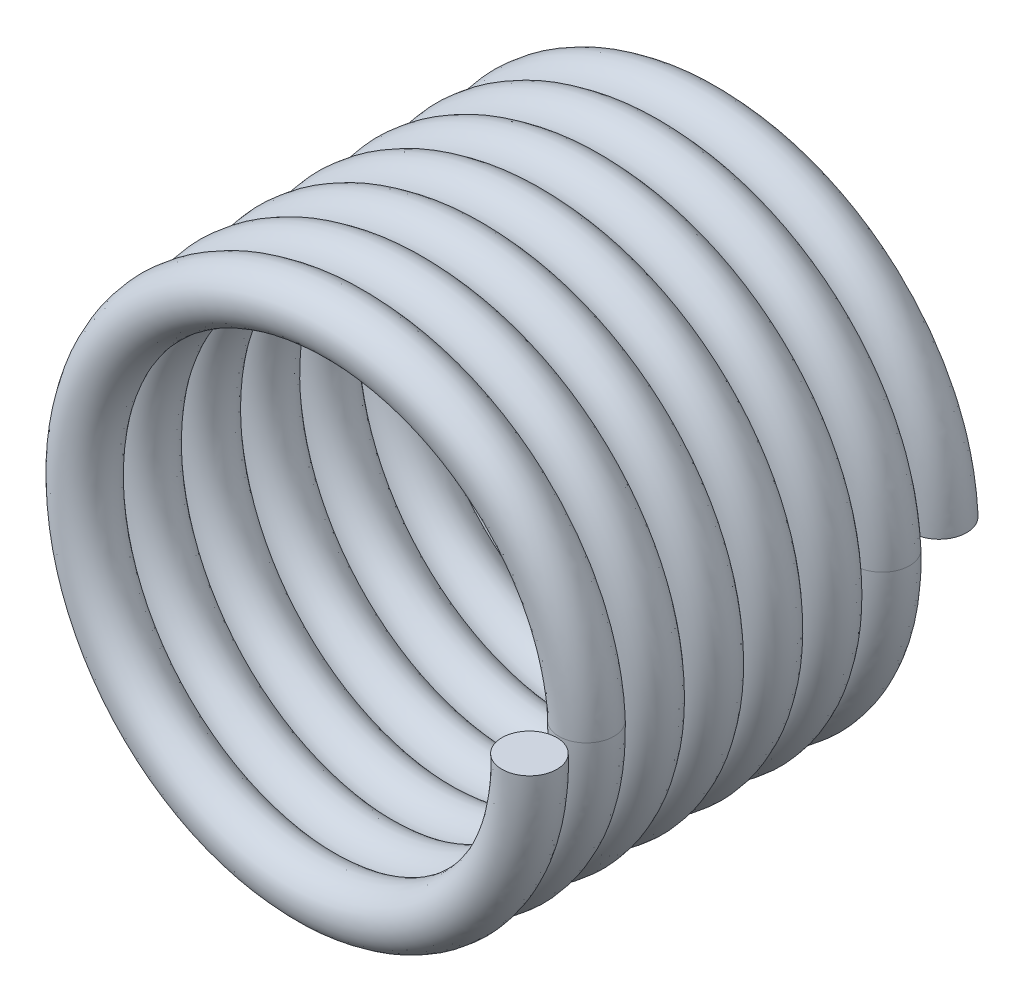
from build123d import *

# Parameters (mm, degrees)
SKETCH5_R = 0.3302


with BuildPart() as part:
    # Sweep1: sweep along a curve in space
    with BuildLine() as sweep1_path:
        add(Edge.make_bspline(
            [(3.175, 0, 0), (3.175, -0.412944338, -0.014195981), (3.009683692, -1.247861375, -0.042904974), (2.303512171, -2.303188068, -0.085713619), (1.246651804, -3.009770535, -0.12859055), (0, -3.257634885, -0.171449183), (-1.246651804, -3.009689925, -0.214312719), (-2.303512171, -2.303510509, -0.257174942), (-3.009683692, -1.246652219, -0.300037515), (-3.257658154, 0, -0.3429), (-3.009683692, 1.246652219, -0.385762485), (-2.303512171, 2.303510509, -0.428625058), (-1.246651804, 3.009689925, -0.471487281), (0, 3.257634885, -0.514350817), (1.246651804, 3.009770535, -0.55720945), (2.303512171, 2.303188068, -0.600086381), (3.009683692, 1.247861375, -0.642895026), (3.175, 0.412944338, -0.671604019), (3.175, 0, -0.6858)],
            knots=[0, 0, 0, 0, 0.0625, 0.125, 0.1875, 0.25, 0.3125, 0.375, 0.4375, 0.5, 0.5625, 0.625, 0.6875, 0.75, 0.8125, 0.875, 0.9375, 1, 1, 1, 1], degree=3))
        add(Edge.make_bspline(
            [(3.175, 0, -0.6858), (3.175, -0.412944576, -0.700521766), (3.009683692, -1.247861264, -0.730294043), (2.303512171, -2.303188097, -0.774688199), (1.246651804, -3.009770528, -0.819153162), (0, -3.257634886, -0.863599153), (-1.246651804, -3.009689927, -0.908050227), (-2.303512171, -2.303510501, -0.952499939), (-3.009683692, -1.246652251, -0.996950016), (-3.257658154, 1.2e-07, -1.041399996), (-3.009683692, 1.246651772, -1.085850001), (-2.303512171, 2.30351218, -1.1303), (-1.246651804, 3.00968369, -1.17475), (0, 3.257658154, -1.2192), (1.246651804, 3.009683692, -1.26365), (2.303512171, 2.303512171, -1.3081), (3.009683692, 1.246651804, -1.35255), (3.257658154, 0, -1.397), (3.009683692, -1.246651804, -1.44145), (2.303512171, -2.303512171, -1.4859), (1.246651804, -3.009683692, -1.53035), (0, -3.257658154, -1.5748), (-1.246651804, -3.009683692, -1.61925), (-2.303512171, -2.303512171, -1.6637), (-3.009683692, -1.246651804, -1.70815), (-3.257658154, 0, -1.7526), (-3.009683692, 1.246651804, -1.79705), (-2.303512171, 2.303512171, -1.8415), (-1.246651804, 3.009683692, -1.88595), (0, 3.257658154, -1.9304), (1.246651804, 3.009683692, -1.97485), (2.303512171, 2.303512171, -2.0193), (3.009683692, 1.246651804, -2.06375), (3.257658154, 0, -2.1082), (3.009683692, -1.246651804, -2.15265), (2.303512171, -2.303512171, -2.1971), (1.246651804, -3.009683692, -2.24155), (0, -3.257658154, -2.286), (-1.246651804, -3.009683692, -2.33045), (-2.303512171, -2.303512171, -2.3749), (-3.009683692, -1.246651804, -2.41935), (-3.257658154, 0, -2.4638), (-3.009683692, 1.246651804, -2.50825), (-2.303512171, 2.303512171, -2.5527), (-1.246651804, 3.009683692, -2.59715), (0, 3.257658154, -2.6416), (1.246651804, 3.009683692, -2.68605), (2.303512171, 2.303512171, -2.7305), (3.009683692, 1.246651804, -2.77495), (3.257658154, 0, -2.8194), (3.009683692, -1.246651804, -2.86385), (2.303512171, -2.303512171, -2.9083), (1.246651804, -3.009683692, -2.95275), (0, -3.257658154, -2.9972), (-1.246651804, -3.009683692, -3.04165), (-2.303512171, -2.303512171, -3.0861), (-3.009683692, -1.246651804, -3.13055), (-3.257658154, 0, -3.175), (-3.009683692, 1.246651804, -3.21945), (-2.303512171, 2.303512171, -3.2639), (-1.246651804, 3.009683692, -3.30835), (0, 3.257658154, -3.3528), (1.246651804, 3.009683692, -3.39725), (2.303512171, 2.303512171, -3.4417), (3.009683692, 1.246651804, -3.48615), (3.257658154, 0, -3.5306), (3.009683692, -1.246651804, -3.57505), (2.303512171, -2.303512171, -3.6195), (1.246651804, -3.009683692, -3.66395), (0, -3.257658154, -3.7084), (-1.246651804, -3.00968369, -3.75285), (-2.303512171, -2.30351218, -3.7973), (-3.009683692, -1.246651772, -3.841749999), (-3.257658154, -1.2e-07, -3.886200004), (-3.009683692, 1.246652251, -3.930649984), (-2.303512171, 2.303510501, -3.975100061), (-1.246651804, 3.009689927, -4.019549773), (0, 3.257634886, -4.064000847), (1.246651804, 3.009770528, -4.108446838), (2.303512171, 2.303188097, -4.152911801), (3.009683692, 1.247861264, -4.197305957), (3.175, 0.412944576, -4.227078234), (3.175, 0, -4.2418)],
            knots=[0, 0, 0, 0, 0.0125, 0.025, 0.0375, 0.05, 0.0625, 0.075, 0.0875, 0.1, 0.1125, 0.125, 0.1375, 0.15, 0.1625, 0.175, 0.1875, 0.2, 0.2125, 0.225, 0.2375, 0.25, 0.2625, 0.275, 0.2875, 0.3, 0.3125, 0.325, 0.3375, 0.35, 0.3625, 0.375, 0.3875, 0.4, 0.4125, 0.425, 0.4375, 0.45, 0.4625, 0.475, 0.4875, 0.5, 0.5125, 0.525, 0.5375, 0.55, 0.5625, 0.575, 0.5875, 0.6, 0.6125, 0.625, 0.6375, 0.65, 0.6625, 0.675, 0.6875, 0.7, 0.7125, 0.725, 0.7375, 0.75, 0.7625, 0.775, 0.7875, 0.8, 0.8125, 0.825, 0.8375, 0.85, 0.8625, 0.875, 0.8875, 0.9, 0.9125, 0.925, 0.9375, 0.95, 0.9625, 0.975, 0.9875, 1, 1, 1, 1], degree=3))
        add(Edge.make_bspline(
            [(3.175, 0, -4.2418), (3.175, -0.412944338, -4.255995981), (3.009683692, -1.247861375, -4.284704974), (2.303512171, -2.303188068, -4.327513619), (1.246651804, -3.009770535, -4.37039055), (0, -3.257634885, -4.413249183), (-1.246651804, -3.009689925, -4.456112719), (-2.303512171, -2.303510509, -4.498974942), (-3.009683692, -1.246652219, -4.541837515), (-3.257658154, 0, -4.5847), (-3.009683692, 1.246652219, -4.627562485), (-2.303512171, 2.303510509, -4.670425058), (-1.246651804, 3.009689925, -4.713287281), (0, 3.257634885, -4.756150817), (1.246651804, 3.009770535, -4.79900945), (2.303512171, 2.303188068, -4.841886381), (3.009683692, 1.247861375, -4.884695026), (3.175, 0.412944338, -4.913404019), (3.175, 0, -4.9276)],
            knots=[0, 0, 0, 0, 0.0625, 0.125, 0.1875, 0.25, 0.3125, 0.375, 0.4375, 0.5, 0.5625, 0.625, 0.6875, 0.75, 0.8125, 0.875, 0.9375, 1, 1, 1, 1], degree=3))
    # Sketch5 → Sweep1 (sweep)
    with BuildSketch(Plane(origin=(0, 0, 0), x_dir=(1, 0, 0), z_dir=(0, 1, 0))):
        with Locations((2.8448, 0)):
            Circle(SKETCH5_R)
    sweep(path=sweep1_path.line, is_frenet=True, transition=Transition.RIGHT)


solid = part.part
